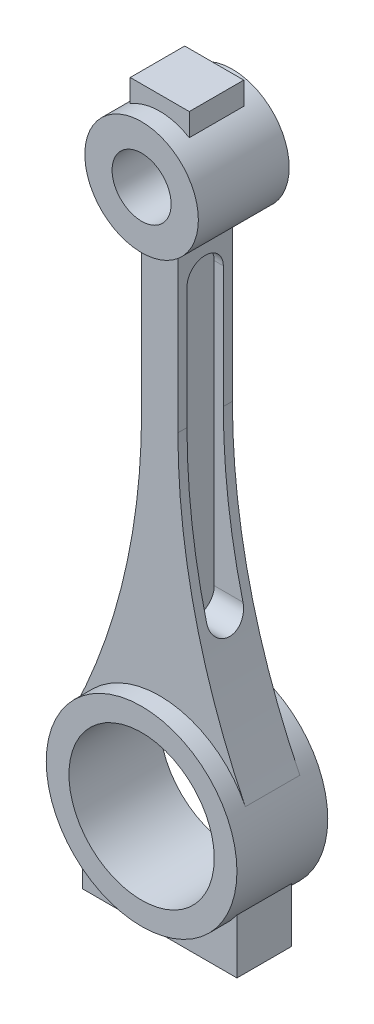
from build123d import *

# Parameters (mm, degrees)
SKETCH1_R             = 12.5
SKETCH1_R_2           = 6.5
BOSS_EXTRUDE2_DEPTH   = 10
SKETCH1_R_3           = 21
SKETCH1_R_4           = 16
BOSS_EXTRUDE2_2_DEPTH = 10
BOSS_EXTRUDE3_DEPTH   = 6
BOSS_EXTRUDE4_DEPTH   = 6
CUT_EXTRUDE1_START    = -6
CUT_EXTRUDE1_DEPTH    = 141.818972185
CUT_EXTRUDE6_START    = -2
CUT_EXTRUDE6_DEPTH    = 149.818972185


with BuildPart() as part:
    # Sketch1 → Boss-Extrude2 (new, symmetric)
    with BuildSketch(Plane.XY):
        Circle(SKETCH1_R)
        Circle(SKETCH1_R_2, mode=Mode.SUBTRACT)
    extrude(amount=BOSS_EXTRUDE2_DEPTH, both=True)



with BuildPart() as body_2:
    # Sketch1 → Boss-Extrude2 2 (new, symmetric)
    with BuildSketch(Plane.XY):
        with Locations((0, -120)):
            Circle(SKETCH1_R_3)
        with Locations((0, -120)):
            Circle(SKETCH1_R_4, mode=Mode.SUBTRACT)
    extrude(amount=BOSS_EXTRUDE2_2_DEPTH, both=True)


with BuildPart() as part_1:
    add(part.part)

    add(body_2.part)  # Boss-Extrude3 merges body 2
    # Sketch1_6 → Boss-Extrude3 (add, symmetric)
    with BuildSketch(Plane.XY):
        with BuildLine():
            ThreePointArc((4, -11.842719282), (0, -12.5), (-4, -11.842719282))
            Line((-4, -11.842719282), (-4, -46.842719282))
            ThreePointArc((-4, -46.842719282), (-7.760864887, -79.642724072), (-18.848249172, -110.740221215))
            ThreePointArc((-18.848249172, -110.740221215), (0, -99), (18.848249172, -110.740221215))
            ThreePointArc((18.848249172, -110.740221215), (7.760864887, -79.642724072), (4, -46.842719282))
            Line((4, -46.842719282), (4, -11.842719282))
        make_face()
        with BuildLine():
            ThreePointArc((17, -132.328828006), (0, -141), (-17, -132.328828006))
            Line((-17, -132.328828006), (-17, -144.328828006))
            Line((-17, -144.328828006), (17, -144.328828006))
            Line((17, -144.328828006), (17, -132.328828006))
        make_face()
    extrude(amount=BOSS_EXTRUDE3_DEPTH, both=True)

    # Sketch2 → Boss-Extrude4 (add, symmetric)
    with BuildSketch(Plane.XY):
        with BuildLine():
            Line((6.5, 15.677078252), (6.5, 10.677078252))
            ThreePointArc((6.5, 10.677078252), (0, 12.5), (-6.5, 10.677078252))
            Line((-6.5, 10.677078252), (-6.5, 15.677078252))
            Line((-6.5, 15.677078252), (6.5, 15.677078252))
        make_face()
    extrude(amount=BOSS_EXTRUDE4_DEPTH, both=True)

    # Sketch3 → Cut-Extrude1 (cut, through all)
    with BuildSketch(Plane(origin=(4, 0, 0), x_dir=(0, 0, -1), z_dir=(1, 0, 0)).offset(CUT_EXTRUDE1_START)):
        with BuildLine():
            Line((-4, -82), (-4, -20))
            ThreePointArc((-4, -20), (0, -16), (4, -20))
            Line((4, -20), (4, -82))
            ThreePointArc((4, -82), (0, -86), (-4, -82))
        make_face()
    extrude(amount=-CUT_EXTRUDE1_DEPTH, mode=Mode.SUBTRACT)

    # Sketch3_5 → Cut-Extrude6 (cut, through all)
    with BuildSketch(Plane(origin=(4, 0, 0), x_dir=(0, 0, -1), z_dir=(1, 0, 0)).offset(CUT_EXTRUDE6_START)):
        with BuildLine():
            Line((-4, -82), (-4, -20))
            ThreePointArc((-4, -20), (0, -16), (4, -20))
            Line((4, -20), (4, -82))
            ThreePointArc((4, -82), (0, -86), (-4, -82))
        make_face()
    extrude(amount=CUT_EXTRUDE6_DEPTH, mode=Mode.SUBTRACT)


solid = part_1.part
